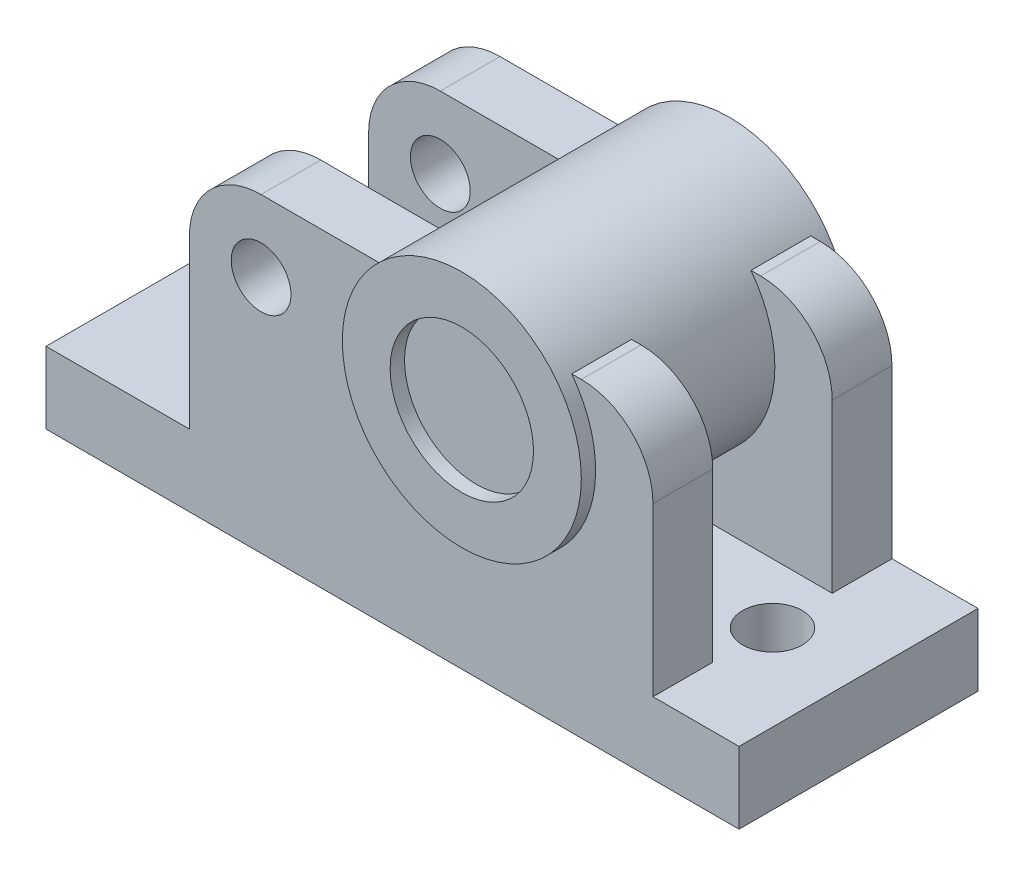
from build123d import *

# Parameters (mm, degrees)
SKETCH1_W           = 290
SKETCH1_H           = 30
BOSS_EXTRUDE1_DEPTH = 50
CUT_EXTRUDE3_REACH  = 32
SKETCH5_R           = 12.5
SKETCH7_W           = 194
SKETCH7_H           = 100
SKETCH7_R           = 12.5
BOSS_EXTRUDE2_DEPTH = 25
FILLET1_R           = 30
SKETCH8_R           = 12.5
BOSS_EXTRUDE3_DEPTH = 25
SKETCH9_R           = 50
SKETCH9_R_2         = 30
BOSS_EXTRUDE4_DEPTH = 56


with BuildPart() as part:
    # Sketch1 → Boss-Extrude1 (new body, symmetric)
    with BuildSketch(Plane.XY):
        with Locations((145, 15)):
            Rectangle(SKETCH1_W, SKETCH1_H)
    extrude(amount=BOSS_EXTRUDE1_DEPTH, both=True)

    # Sketch5 → Cut-Extrude3 (cut, up to next)
    with BuildSketch(Plane(origin=(0, 0, 0), x_dir=(1, 0, 0), z_dir=(0, 1, 0)), mode=Mode.PRIVATE) as cut_extrude3_sk1:
        with Locations(Location((36, 0, 0), (0, 0, 90))):  # turned: the seam where the file's is
            Circle(SKETCH5_R)
    cut_extrude3_tool1 = extrude(cut_extrude3_sk1.sketch, amount=CUT_EXTRUDE3_REACH, mode=Mode.PRIVATE) & part.part
    add(cut_extrude3_tool1.solids().sort_by_distance((36, 0, 0))[0], mode=Mode.SUBTRACT)
    # Sketch5 → Cut-Extrude3 (cut, up to next)
    with BuildSketch(Plane(origin=(0, 0, 0), x_dir=(1, 0, 0), z_dir=(0, 1, 0)), mode=Mode.PRIVATE) as cut_extrude3_sk2:
        with Locations(Location((254, 0, 0), (0, 0, 90))):  # turned: the seam where the file's is
            Circle(SKETCH5_R)
    cut_extrude3_tool2 = extrude(cut_extrude3_sk2.sketch, amount=CUT_EXTRUDE3_REACH, mode=Mode.PRIVATE) & part.part
    add(cut_extrude3_tool2.solids().sort_by_distance((254, 0, 0))[0], mode=Mode.SUBTRACT)

    # Sketch7 → Boss-Extrude2 (add)
    with BuildSketch(Plane.XY.offset(50)):
        with Locations((157, 80)):
            Rectangle(SKETCH7_W, SKETCH7_H)
        with Locations((90, 100)):
            Circle(SKETCH7_R, mode=Mode.SUBTRACT)
    extrude(amount=-BOSS_EXTRUDE2_DEPTH)

    # Fillet1
    fillet1_edges = [part.edges().sort_by_distance(p)[0] for p in [
        (254, 130, 37.5),
        (60, 130, 37.5),
    ]]
    fillet(fillet1_edges, radius=FILLET1_R)

    # Sketch8 → Boss-Extrude3 (add)
    with BuildSketch(Plane(origin=(0, 0, -50), x_dir=(-1, 0, 0), z_dir=(0, 0, -1))):
        with BuildLine():
            Line((-90, 130), (-224, 130))
            ThreePointArc((-224, 130), (-245.213203436, 121.213203436), (-254, 100))
            Line((-254, 100), (-254, 30))
            Line((-254, 30), (-60, 30))
            Line((-60, 30), (-60, 100))
            ThreePointArc((-60, 100), (-68.786796564, 121.213203436), (-90, 130))
        make_face()
        with Locations(Location((-90, 100, 0), (0, 0, 180))):  # turned: the seam where the file's is
            Circle(SKETCH8_R, mode=Mode.SUBTRACT)
    extrude(amount=-BOSS_EXTRUDE3_DEPTH)

    # Sketch9 → Boss-Extrude4 (add, symmetric)
    with BuildSketch(Plane.XY):
        with Locations((180, 100)):
            Circle(SKETCH9_R)
        with Locations(Location((180, 100, 0), (0, 0, 180))):  # turned: the seam where the file's is
            Circle(SKETCH9_R_2, mode=Mode.SUBTRACT)
    extrude(amount=BOSS_EXTRUDE4_DEPTH, both=True)


solid = part.part
